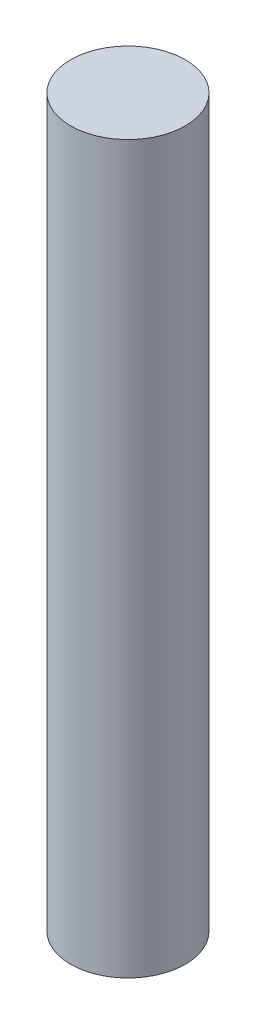
from build123d import *

# Parameters (mm, degrees)
SKETCH1_R           = 1.5
BOSS_EXTRUDE1_DEPTH = 19


with BuildPart() as part:
    # Sketch1 → Boss-Extrude1 (new body)
    with BuildSketch(Plane(origin=(0, 0, 0), x_dir=(1, 0, 0), z_dir=(0, 1, 0))):
        Circle(SKETCH1_R)
    extrude(amount=BOSS_EXTRUDE1_DEPTH)


solid = part.part
